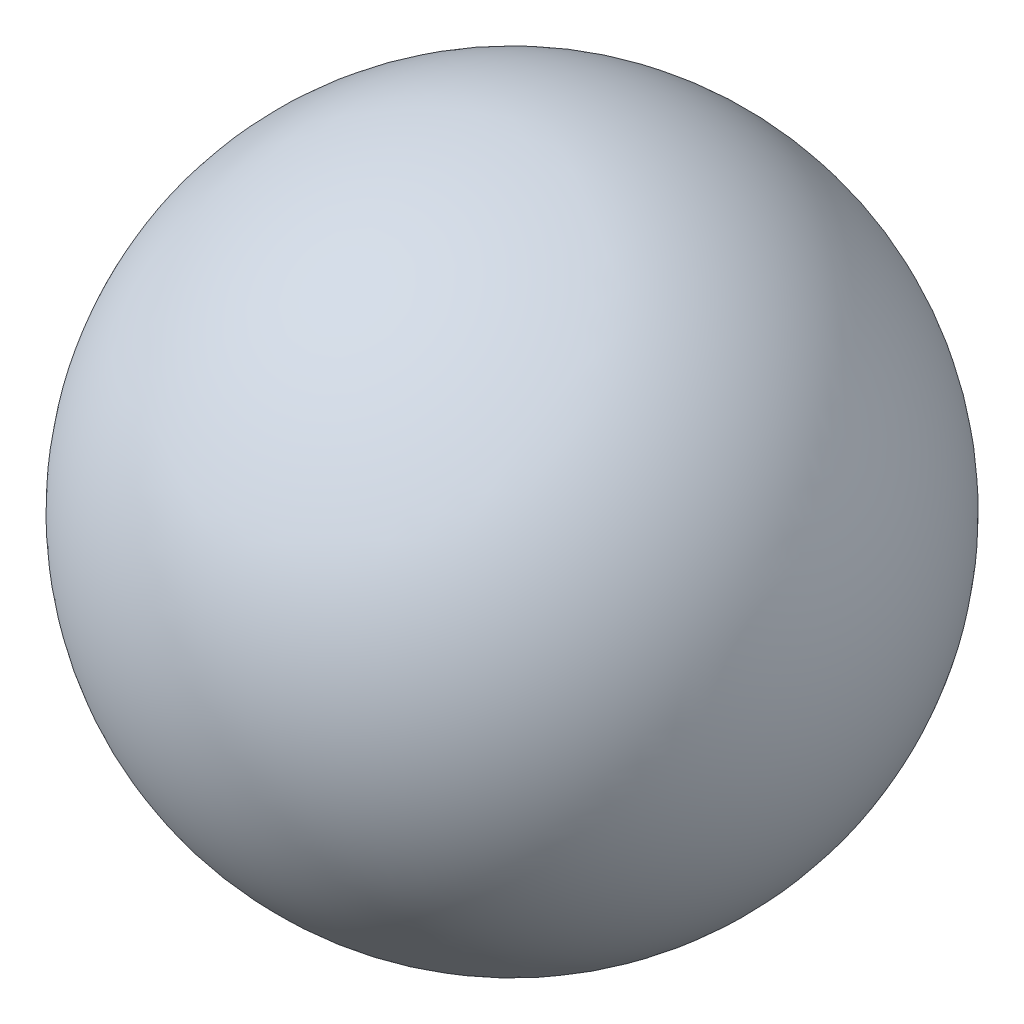
from build123d import *


with BuildPart() as part:
    # Croquis1 → Revolución1 (revolve)
    with BuildSketch(Plane.XY):
        with BuildLine():
            Line((10.572, 15), (3.428, 15))
            ThreePointArc((3.428, 15), (7, 18.572), (10.572, 15))
        make_face()
    revolve(axis=Axis((50, 15, 0), (-1, 0, 0)))


solid = part.part
